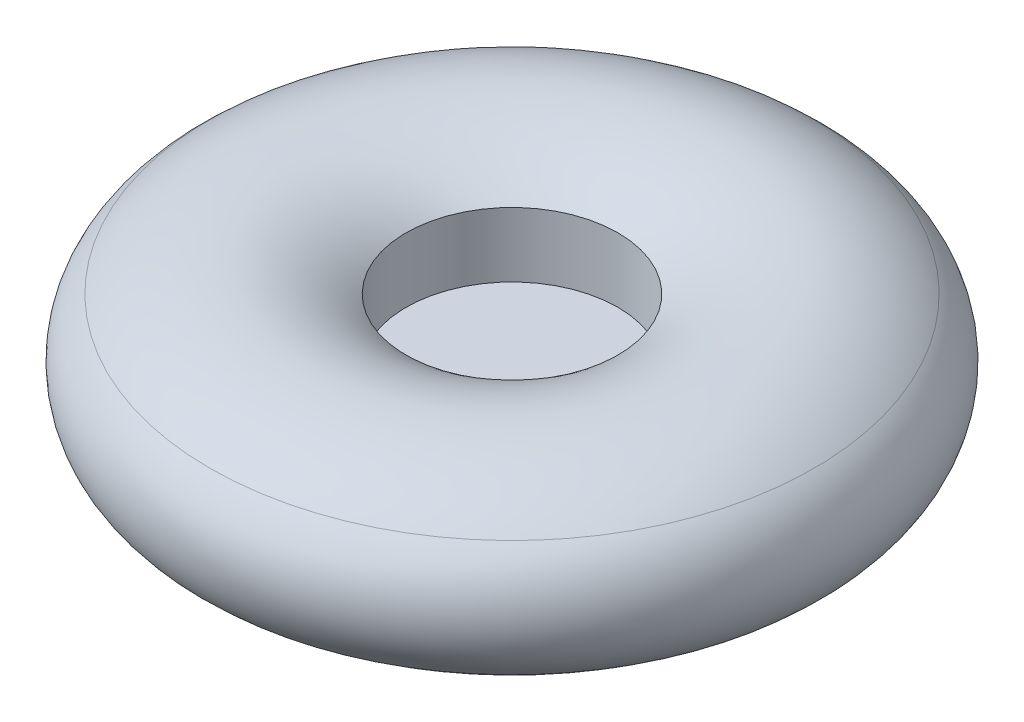
from build123d import *


with BuildPart() as part:
    # Sketch1 → Revolve1 (revolve)
    with BuildSketch(Plane.XY):
        with BuildLine():
            Line((0, 0), (0, 1.928074015))
            Line((0, 1.928074015), (57.15, 1.928074015))
            Line((57.15, 1.928074015), (57.15, 36.750137113))
            ThreePointArc((57.15, 36.750137113), (110.052624852, 55.65284987), (162.955249704, 36.750137113))
            ThreePointArc((162.955249704, 36.750137113), (177.8, 5.399105858), (162.955249704, -25.951925396))
            ThreePointArc((162.955249704, -25.951925396), (110.052624852, -44.854638153), (57.15, -25.951925396))
            Line((57.15, -25.951925396), (57.15, -2.834425985))
            Line((57.15, -2.834425985), (0, -2.834425985))
            Line((0, -2.834425985), (0, 0))
        make_face()
    revolve(axis=Axis((0, 0, 0), (0, 1, 0)))


solid = part.part
